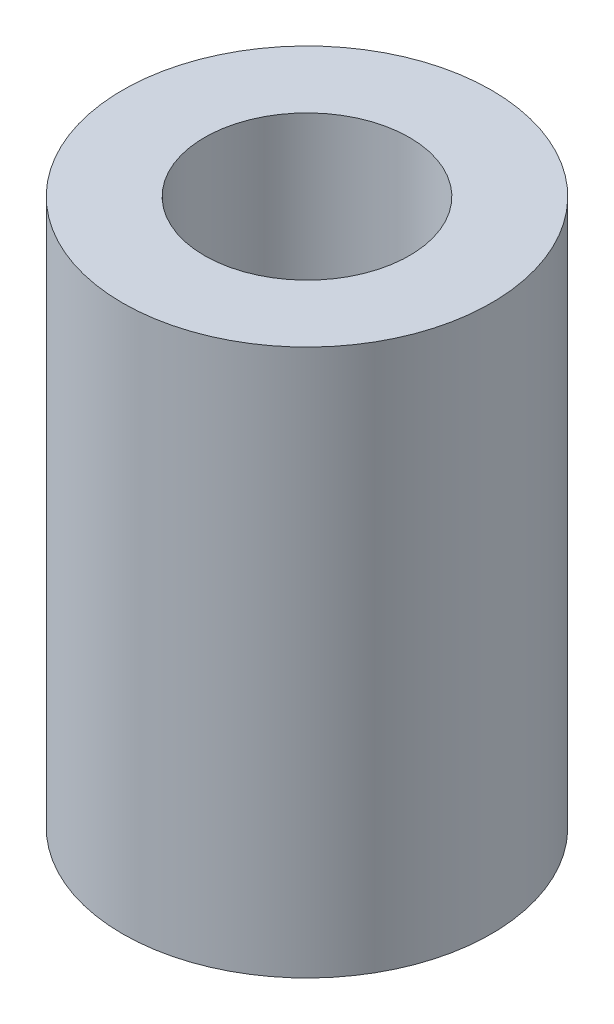
from build123d import *

# Parameters (mm, degrees)
ESBO_O1_R                = 3.375
ESBO_O1_R_2              = 1.875
RESSALTO_EXTRUS_O1_DEPTH = 10


with BuildPart() as part:
    # Esboço1 → Ressalto-extrusão1 (new body)
    with BuildSketch(Plane(origin=(0, 0, 0), x_dir=(1, 0, 0), z_dir=(0, 1, 0))):
        Circle(ESBO_O1_R)
        Circle(ESBO_O1_R_2, mode=Mode.SUBTRACT)
    extrude(amount=RESSALTO_EXTRUS_O1_DEPTH)


solid = part.part
